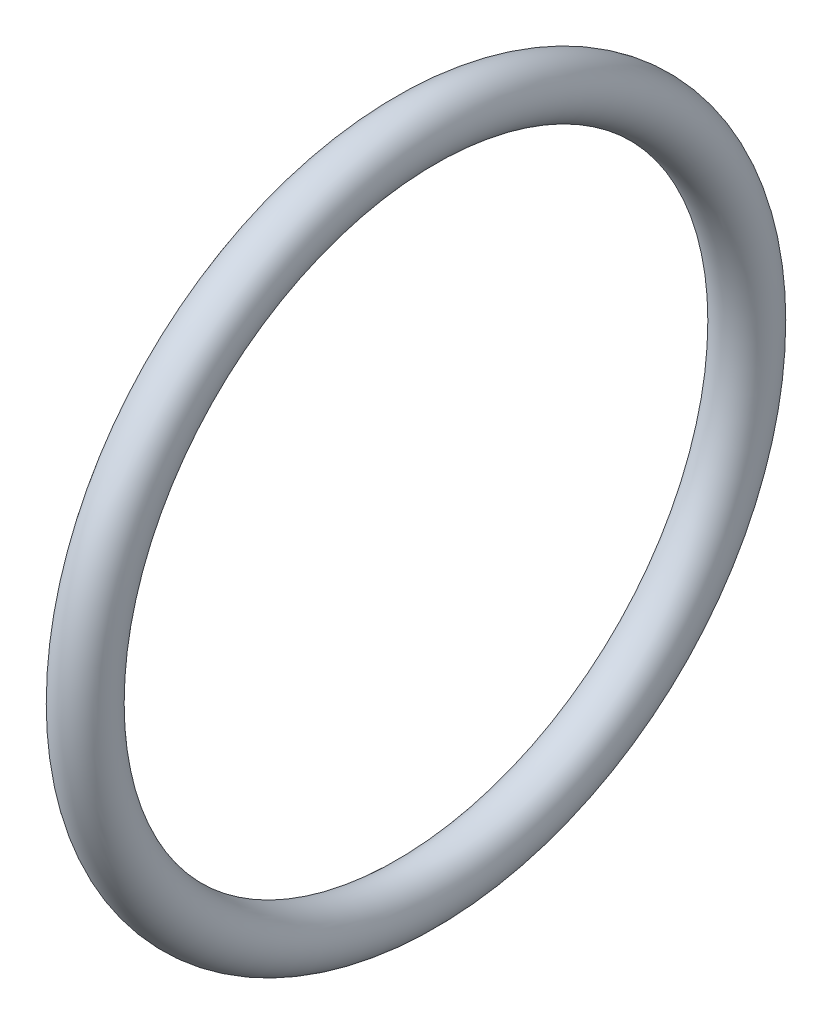
from build123d import *

# Parameters (mm, degrees)
SKETCH1_R = 1


with BuildPart() as part:
    # Sketch1 → Revolve1 (revolve)
    with BuildSketch(Plane.XY):
        with Locations((0, 12)):
            Circle(SKETCH1_R)
    revolve(axis=Axis((-22.628571429, 0, 0), (1, 0, 0)))


solid = part.part
